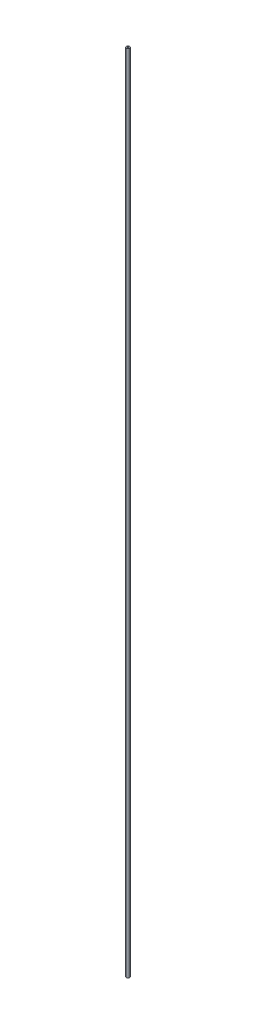
from build123d import *

# Parameters (mm, degrees)
SKETCH1_R           = 3.175
SKETCH1_R_2         = 1.524
BOSS_EXTRUDE1_DEPTH = 762


with BuildPart() as part:
    # Sketch1 → Boss-Extrude1 (new body, symmetric)
    with BuildSketch(Plane(origin=(0, 0, 0), x_dir=(1, 0, 0), z_dir=(0, 1, 0))):
        Circle(SKETCH1_R)
        Circle(SKETCH1_R_2, mode=Mode.SUBTRACT)
    extrude(amount=BOSS_EXTRUDE1_DEPTH, both=True)


solid = part.part
